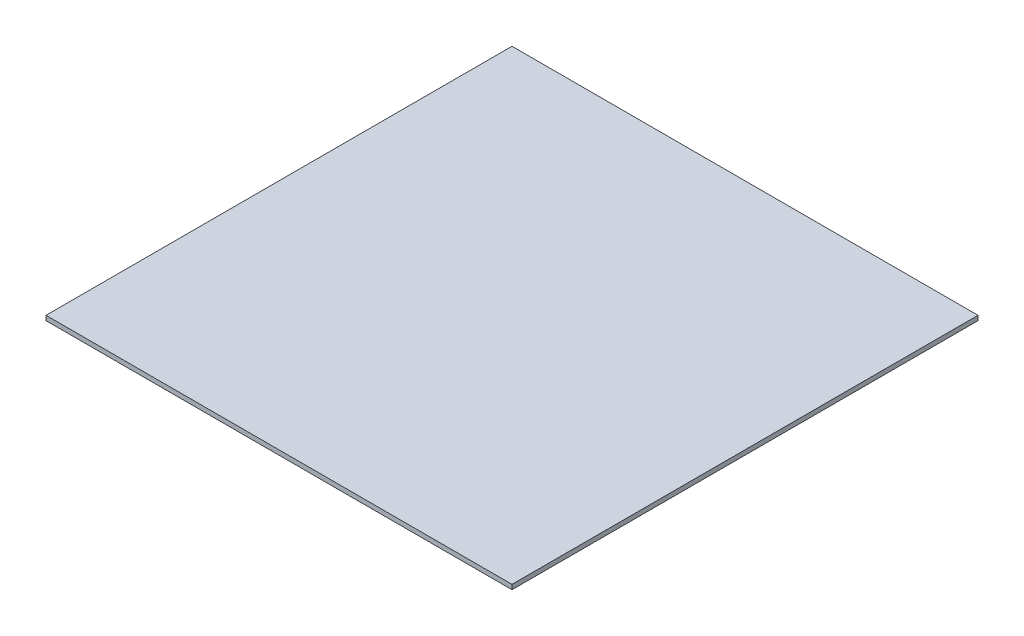
from build123d import *

# Parameters (mm, degrees)
SKETCH1_W           = 508
SKETCH1_H           = 508
BOSS_EXTRUDE1_DEPTH = 5.08


with BuildPart() as part:
    # Sketch1 → Boss-Extrude1 (new body)
    with BuildSketch(Plane(origin=(0, 0, 0), x_dir=(1, 0, 0), z_dir=(0, 1, 0))):
        with Locations((-254, -254)):
            Rectangle(SKETCH1_W, SKETCH1_H)
    extrude(amount=BOSS_EXTRUDE1_DEPTH)


solid = part.part
